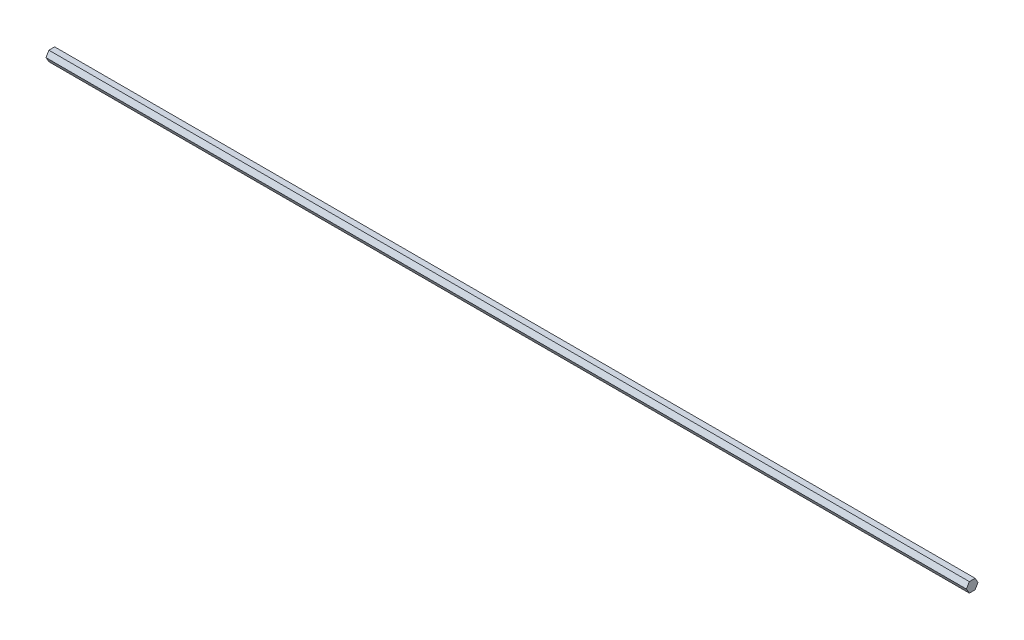
from build123d import *

# Parameters (mm, degrees)
BOSS_EXTRUDE1_DEPTH = 119.38


with BuildPart() as part:
    # Sketch1 → Boss-Extrude1 (new, symmetric)
    with BuildSketch(Plane(origin=(0, 0, 0), x_dir=(0, 0, -1), z_dir=(1, 0, 0))):
        Polygon((1.5, 0), (0.75, 1.299038106), (-0.75, 1.299038106), (-1.5, 0), (-0.75, -1.299038106), (0.75, -1.299038106), align=None)
    extrude(amount=BOSS_EXTRUDE1_DEPTH, both=True)


solid = part.part
